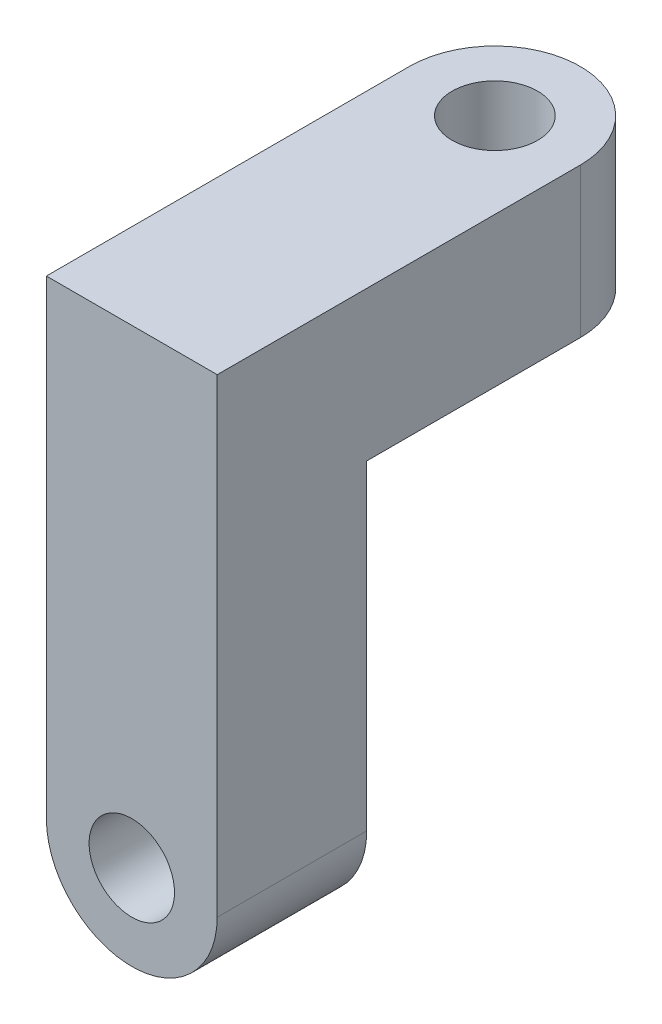
from build123d import *

# Parameters (mm, degrees)
SKETCH2_R           = 1.5
BOSS_EXTRUDE1_DEPTH = 7
SKETCH3_R           = 1.5
BOSS_EXTRUDE2_DEPTH = 7
SKETCH4_R           = 2
CUT_EXTRUDE1_DEPTH  = 10
SKETCH5_R           = 2
CUT_EXTRUDE2_DEPTH  = 10


with BuildPart() as part:
    # Sketch2 → Boss-Extrude1 (new body)
    with BuildSketch(Plane.XY):
        with BuildLine():
            Line((-4, -15), (-4, 0))
            Line((-4, 0), (4, 0))
            Line((4, 0), (4, -15))
            ThreePointArc((4, -15), (0, -19), (-4, -15))
        make_face()
        with Locations((0, -15)):
            Circle(SKETCH2_R, mode=Mode.SUBTRACT)
    extrude(amount=BOSS_EXTRUDE1_DEPTH)

    # Sketch3 → Boss-Extrude2 (add)
    with BuildSketch(Plane(origin=(0, 0, 0), x_dir=(1, 0, 0), z_dir=(0, 1, 0))):
        with BuildLine():
            Line((-4, 10), (-4, -7))
            Line((-4, -7), (4, -7))
            Line((4, -7), (4, 10))
            ThreePointArc((4, 10), (0, 14), (-4, 10))
        make_face()
        with Locations((0, 10)):
            Circle(SKETCH3_R, mode=Mode.SUBTRACT)
    extrude(amount=BOSS_EXTRUDE2_DEPTH)

    # Sketch4 → Cut-Extrude1 (cut)
    with BuildSketch(Plane(origin=(0, 7, 0), x_dir=(1, 0, 0), z_dir=(0, 1, 0))):
        with Locations((0, 10)):
            Circle(SKETCH4_R)
    extrude(amount=-CUT_EXTRUDE1_DEPTH, mode=Mode.SUBTRACT)

    # Sketch5 → Cut-Extrude2 (cut)
    with BuildSketch(Plane.XY.offset(7)):
        with Locations((0, -15)):
            Circle(SKETCH5_R)
    extrude(amount=-CUT_EXTRUDE2_DEPTH, mode=Mode.SUBTRACT)


solid = part.part
